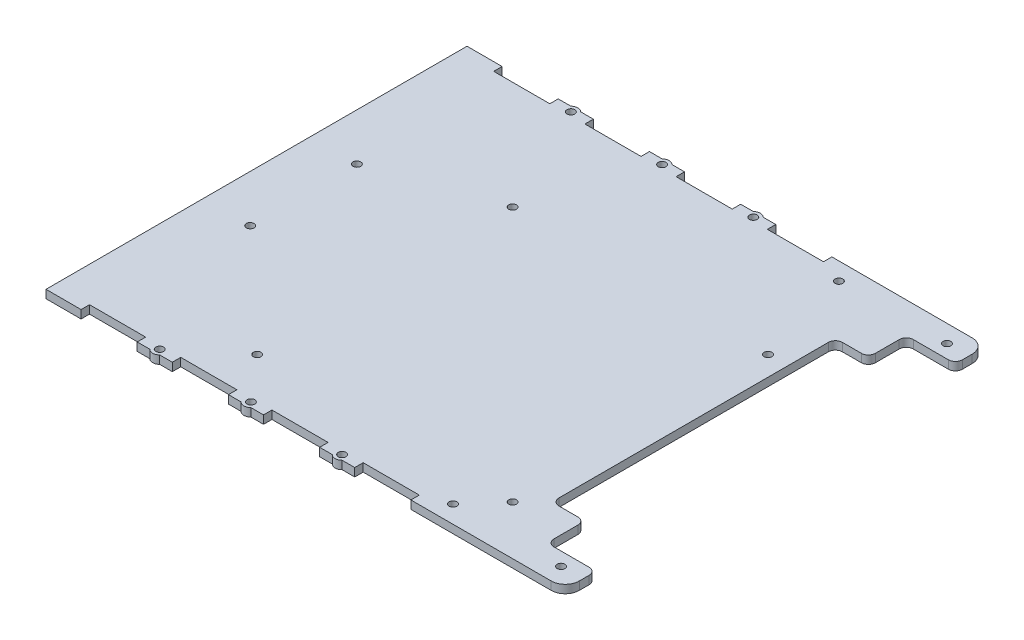
from build123d import *

# Parameters (mm, degrees)
SKETCH2_W           = 187.96
SKETCH2_H           = 152.4
BOSS_EXTRUDE1_DEPTH = 2.9718
SKETCH4_W           = 20.32
SKETCH4_H           = 3.048
SKETCH4_R           = 1.397
CUT_EXTRUDE1_DEPTH  = 5.08
BOSS_EXTRUDE2_DEPTH = 2.9718
FILLET1_R           = 5.08
CUT_EXTRUDE2_DEPTH  = 5.08
FILLET2_R           = 2.54
FILLET3_R           = 2.54
SKETCH7_R           = 1.397
CUT_EXTRUDE3_DEPTH  = 5.08
FILLET5_R           = 2.54
FILLET6_R           = 2.54


with BuildPart() as part:
    # Sketch2 → Boss-Extrude1 (new body)
    with BuildSketch(Plane(origin=(0, 0, 0), x_dir=(1, 0, 0), z_dir=(0, 1, 0))):
        with Locations((24.975168434, 0)):
            Rectangle(SKETCH2_W, SKETCH2_H)
    extrude(amount=BOSS_EXTRUDE1_DEPTH)

    # Sketch4 → Cut-Extrude1 (cut)
    with BuildSketch(Plane(origin=(0, 2.9718, 0), x_dir=(1, 0, 0), z_dir=(0, 1, 0))):
        with Locations((-46.144831566, -74.676)):
            Rectangle(SKETCH4_W, SKETCH4_H)
        with Locations((-46.144831566, 74.676)):
            Rectangle(SKETCH4_W, SKETCH4_H)
        with Locations((-13.124831566, -74.676)):
            Rectangle(SKETCH4_W, SKETCH4_H)
        with Locations((-13.124831566, 74.676)):
            Rectangle(SKETCH4_W, SKETCH4_H)
        with Locations((19.895168434, -74.676)):
            Rectangle(SKETCH4_W, SKETCH4_H)
        with Locations((19.895168434, 74.676)):
            Rectangle(SKETCH4_W, SKETCH4_H)
        with Locations((52.915168434, -74.676)):
            Rectangle(SKETCH4_W, SKETCH4_H)
        with Locations((52.915168434, 74.676)):
            Rectangle(SKETCH4_W, SKETCH4_H)
        with Locations(Location((82.125168434, -58.42, 0), (0, 0, 270))):
            Circle(SKETCH4_R)
        with Locations(Location((-10.330831566, -58.42, 0), (0, 0, 270))):
            Circle(SKETCH4_R)
        with Locations(Location((36.405168434, 74.422, 0), (0, 0, 270))):
            Circle(SKETCH4_R)
        with Locations(Location((3.385168434, 74.422, 0), (0, 0, 270))):
            Circle(SKETCH4_R)
        with Locations(Location((-29.634831566, 74.422, 0), (0, 0, 270))):
            Circle(SKETCH4_R)
        with Locations(Location((36.405168434, -74.422, 0), (0, 0, 270))):
            Circle(SKETCH4_R)
        with Locations(Location((3.385168434, -74.422, 0), (0, 0, 270))):
            Circle(SKETCH4_R)
        with Locations(Location((-29.634831566, -74.422, 0), (0, 0, 270))):
            Circle(SKETCH4_R)
        with Locations(Location((111.081256794, 69.85, 0), (0, 0, 270))):
            Circle(SKETCH4_R)
        with Locations(Location((111.081256794, -69.85, 0), (0, 0, 270))):
            Circle(SKETCH4_R)
        with Locations(Location((71.965256794, 69.85, 0), (0, 0, 270))):
            Circle(SKETCH4_R)
        with Locations(Location((71.965256794, -69.85, 0), (0, 0, 270))):
            Circle(SKETCH4_R)
        with Locations(Location((82.125168434, 34.036, 0), (0, 0, 270))):
            Circle(SKETCH4_R)
        with Locations(Location((-10.330831566, 34.036, 0), (0, 0, 270))):
            Circle(SKETCH4_R)
    extrude(amount=-CUT_EXTRUDE1_DEPTH, mode=Mode.SUBTRACT)

    # Sketch5 → Boss-Extrude2 (add)
    with BuildSketch(Plane(origin=(0, 2.9718, 0), x_dir=(1, 0, 0), z_dir=(0, 1, 0))):
        with BuildLine():
            ThreePointArc((38.185030781, 76.2), (36.405168434, 76.937788936), (34.625306088, 76.2))
            Line((34.625306088, 76.2), (38.185030781, 76.2))
        make_face()
        with BuildLine():
            Line((1.605306088, 76.2), (5.165030781, 76.2))
            ThreePointArc((5.165030781, 76.2), (3.385168434, 76.937788936), (1.605306088, 76.2))
        make_face()
        with BuildLine():
            Line((-31.414693912, 76.2), (-27.854969219, 76.2))
            ThreePointArc((-27.854969219, 76.2), (-29.634831566, 76.937788936), (-31.414693912, 76.2))
        make_face()
        with BuildLine():
            ThreePointArc((-31.414693912, -76.2), (-29.634831566, -76.937788936), (-27.854969219, -76.2))
            Line((-27.854969219, -76.2), (-31.414693912, -76.2))
        make_face()
        with BuildLine():
            ThreePointArc((1.605306088, -76.2), (3.385168434, -76.937788936), (5.165030781, -76.2))
            Line((5.165030781, -76.2), (1.605306088, -76.2))
        make_face()
        with BuildLine():
            ThreePointArc((34.625306088, -76.2), (36.405168434, -76.937788936), (38.185030781, -76.2))
            Line((38.185030781, -76.2), (34.625306088, -76.2))
        make_face()
    extrude(amount=-BOSS_EXTRUDE2_DEPTH)

    # Fillet1
    fillet1_edges = [part.edges().sort_by_distance(p)[0] for p in [
        (118.955168434, 1.4859, 76.2),
        (118.955168434, 1.4859, -76.2),
    ]]
    fillet(fillet1_edges, radius=FILLET1_R)

    # Sketch6 → Cut-Extrude2 (cut)
    with BuildSketch(Plane(origin=(0, 2.9718, 0), x_dir=(1, 0, 0), z_dir=(0, 1, 0))):
        Polygon((118.955168434, -98.380031514), (118.955168434, -65.024), (101.175168434, -65.024), (101.175168434, -51.308), (89.237168434, -51.308), (89.237168434, 51.308), (101.175168434, 51.308), (101.175168434, 65.024), (118.955168434, 65.024), (118.955168434, 98.380031514), (174.761445674, 98.380031514), (174.761445674, -98.380031514), align=None)
    extrude(amount=-CUT_EXTRUDE2_DEPTH, mode=Mode.SUBTRACT)

    # Fillet2
    fillet2_edges = [part.edges().sort_by_distance(p)[0] for p in [
        (101.175168434, 1.4859, -51.308),
    ]]
    fillet(fillet2_edges, radius=FILLET2_R)

    # Fillet3
    fillet3_edges = [part.edges().sort_by_distance(p)[0] for p in [
        (101.175168434, 1.4859, 65.024),
        (101.175168434, 1.4859, 51.308),
        (118.955168434, 1.4859, 65.024),
        (101.175168434, 1.4859, -65.024),
        (118.955168434, 1.4859, -65.024),
    ]]
    fillet(fillet3_edges, radius=FILLET3_R)

    # Sketch7 → Cut-Extrude3 (cut)
    with BuildSketch(Plane(origin=(0, 2.9718, 0), x_dir=(1, 0, 0), z_dir=(0, 1, 0))):
        with Locations(Location((-51.986831566, 19.304, 0), (0, 0, 270))):
            Circle(SKETCH7_R)
        with Locations(Location((-51.986831566, -19.304, 0), (0, 0, 270))):
            Circle(SKETCH7_R)
    extrude(amount=-CUT_EXTRUDE3_DEPTH, mode=Mode.SUBTRACT)

    # Fillet5
    fillet5_edges = [part.edges().sort_by_distance(p)[0] for p in [
        (89.237168434, 1.4859, -51.308),
    ]]
    fillet(fillet5_edges, radius=FILLET5_R)

    # Fillet6
    fillet6_edges = [part.edges().sort_by_distance(p)[0] for p in [
        (89.237168434, 1.4859, 51.308),
    ]]
    fillet(fillet6_edges, radius=FILLET6_R)


solid = part.part
